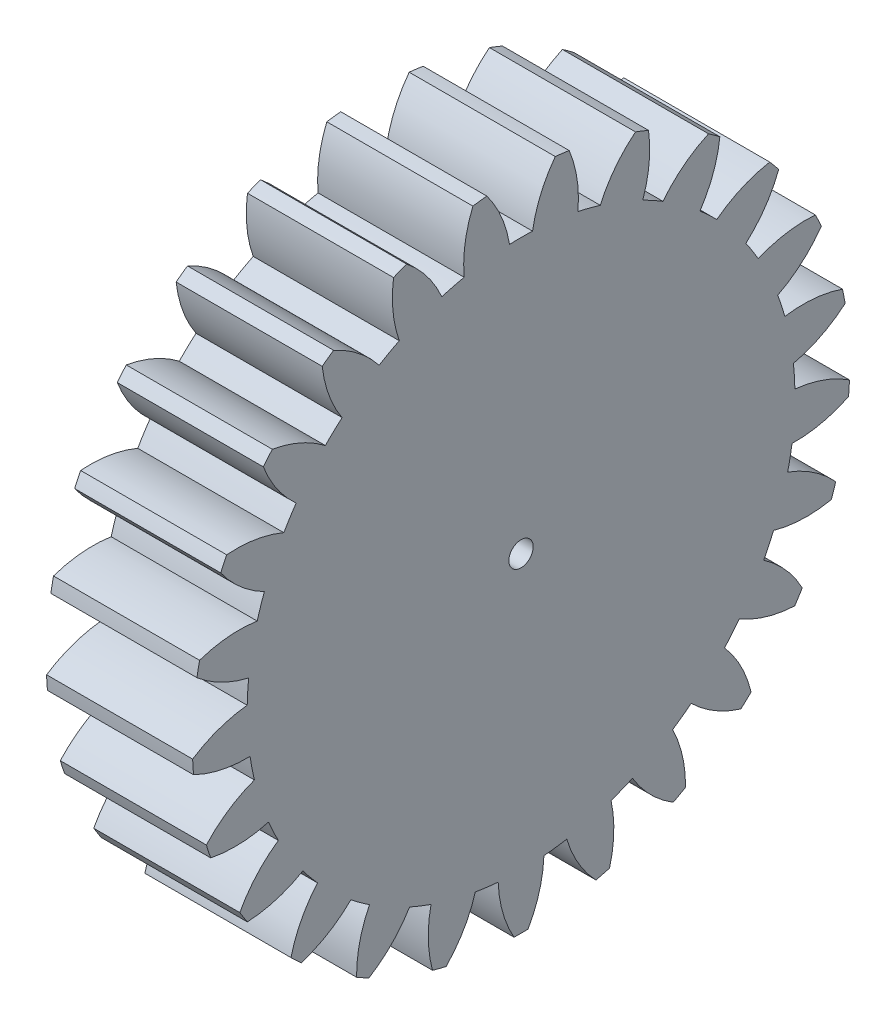
from build123d import *

# Parameters (mm, degrees)
BASPROSKE_W     = 12
BASPROSKE_H     = 27
TOOTHCUT_DEPTH  = 41.024992192
TEETHCUTS_COUNT = 25
TEETHCUTS_ANGLE = 345.6
BORSKE_R        = 1
BORE_DEPTH      = 50.0000508


with BuildPart() as part:
    # BasProSke → Base-Revolve (revolve)
    with BuildSketch(Plane(origin=(0, 0, 0), x_dir=(1, 0, 0), z_dir=(0, 1, 0)), mode=Mode.PRIVATE) as base_revolve_sk:
        with Locations((6, 13.5)):
            Rectangle(BASPROSKE_W, BASPROSKE_H)
    revolve(base_revolve_sk.sketch.rotate(Axis((-10, 0, 0), (1, 0, 0)), 180), axis=Axis((-10, 0, 0), (1, 0, 0)))

    # TooCutSke → ToothCut (cut, through all)
    with BuildSketch(Plane(origin=(0, 0, 0), x_dir=(0, 0, -1), z_dir=(1, 0, 0))):
        with BuildLine():
            ThreePointArc((0.946154762, 22.479096783), (0, 22.499), (-0.946154762, 22.479096783))
            ThreePointArc((-0.946154762, 22.479096783), (-1.62094792, 24.792268013), (-2.829470045, 26.876873784))
            ThreePointArc((-2.829470045, 26.876873784), (0, 27.0254), (2.829470045, 26.876873784))
            ThreePointArc((2.829470045, 26.876873784), (1.62094792, 24.792268013), (0.946154762, 22.479096783))
        make_face()
    toothcut = extrude(amount=TOOTHCUT_DEPTH, mode=Mode.SUBTRACT)

    # TeethCuts: ToothCut ×25 about axis
    teethcuts_axis = Axis((-10, 0, 0), (1, 0, 0))
    for i in range(1, TEETHCUTS_COUNT):
        add(toothcut.rotate(teethcuts_axis, i * TEETHCUTS_ANGLE / (TEETHCUTS_COUNT - 1)), mode=Mode.SUBTRACT)

    # BorSke → Bore (cut, symmetric)
    with BuildSketch(Plane(origin=(0, 0, 0), x_dir=(0, 0, -1), z_dir=(1, 0, 0))):
        with Locations(Location((0, 0, 0), (0, 0, 180))):
            Circle(BORSKE_R)
    extrude(amount=BORE_DEPTH, both=True, mode=Mode.SUBTRACT)


solid = part.part
